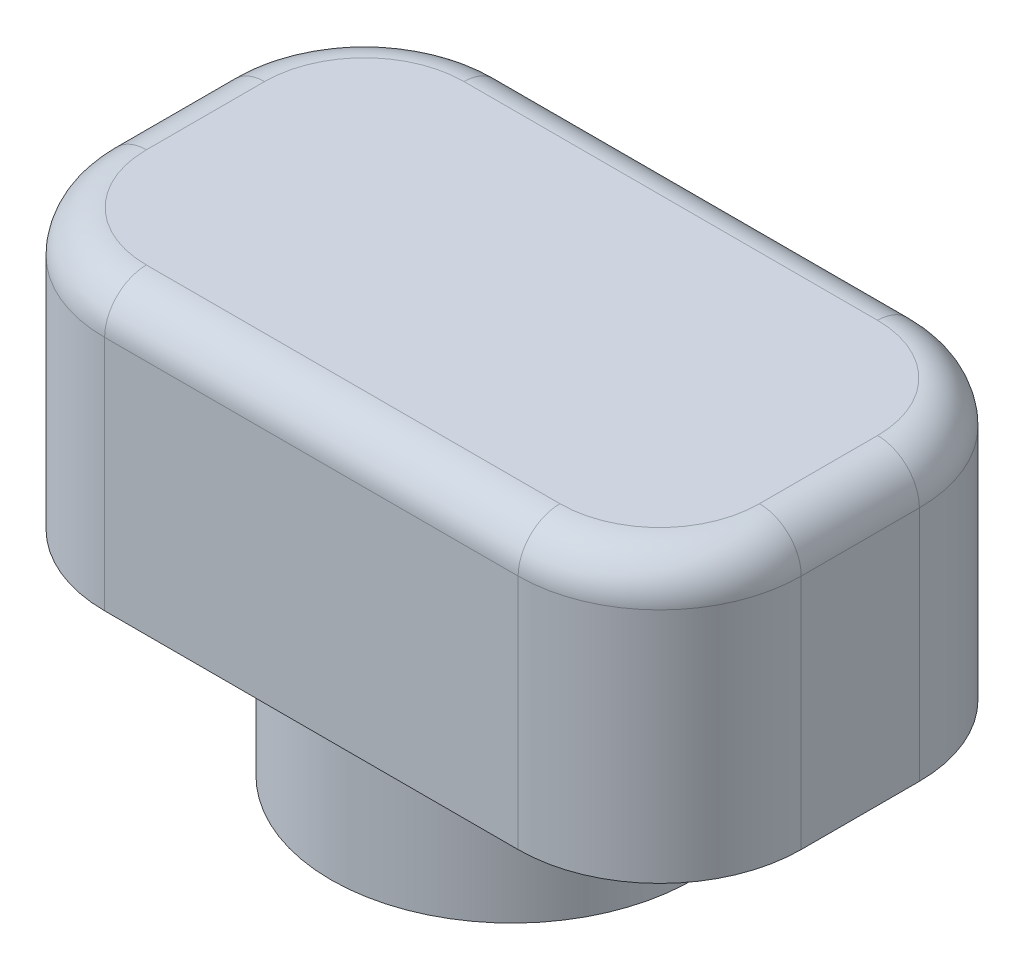
from build123d import *

# Parameters (mm, degrees)
SKETCH1_R           = 3.25
BOSS_EXTRUDE1_DEPTH = 2.5
SKETCH2_R           = 1.75
CUT_EXTRUDE1_DEPTH  = 2.5
SKETCH3_W           = 12.5
SKETCH3_H           = 7.2
BOSS_EXTRUDE2_DEPTH = 5
FILLET1_R           = 2.54
FILLET2_R           = 0.75


with BuildPart() as part:
    # Sketch1 → Boss-Extrude1 (new body)
    with BuildSketch(Plane(origin=(0, 0, 0), x_dir=(1, 0, 0), z_dir=(0, 1, 0))):
        Circle(SKETCH1_R)
    extrude(amount=BOSS_EXTRUDE1_DEPTH)

    # Sketch2 → Cut-Extrude1 (cut)
    with BuildSketch(Plane.XZ):
        Circle(SKETCH2_R)
    extrude(amount=-CUT_EXTRUDE1_DEPTH, mode=Mode.SUBTRACT)

    # Sketch3 → Boss-Extrude2 (add)
    with BuildSketch(Plane(origin=(0, 2.5, 0), x_dir=(1, 0, 0), z_dir=(0, 1, 0))):
        Rectangle(SKETCH3_W, SKETCH3_H)
    extrude(amount=BOSS_EXTRUDE2_DEPTH)

    # Fillet1
    fillet1_edges = [part.edges().sort_by_distance(p)[0] for p in [
        (6.25, 5, 3.6),
        (6.25, 5, -3.6),
        (-6.25, 5, -3.6),
        (-6.25, 5, 3.6),
    ]]
    fillet(fillet1_edges, radius=FILLET1_R)

    # Fillet2
    fillet2_edges = [part.edges().sort_by_distance(p)[0] for p in [
        (-6.25, 7.5, 0),
        (0, 7.5, -3.6),
        (6.25, 7.5, 0),
        (0, 7.5, 3.6),
        (-5.506051224, 7.5, 2.856051224),
        (5.506051224, 7.5, 2.856051224),
        (5.506051224, 7.5, -2.856051224),
        (-5.506051224, 7.5, -2.856051224),
    ]]
    fillet(fillet2_edges, radius=FILLET2_R)


solid = part.part
